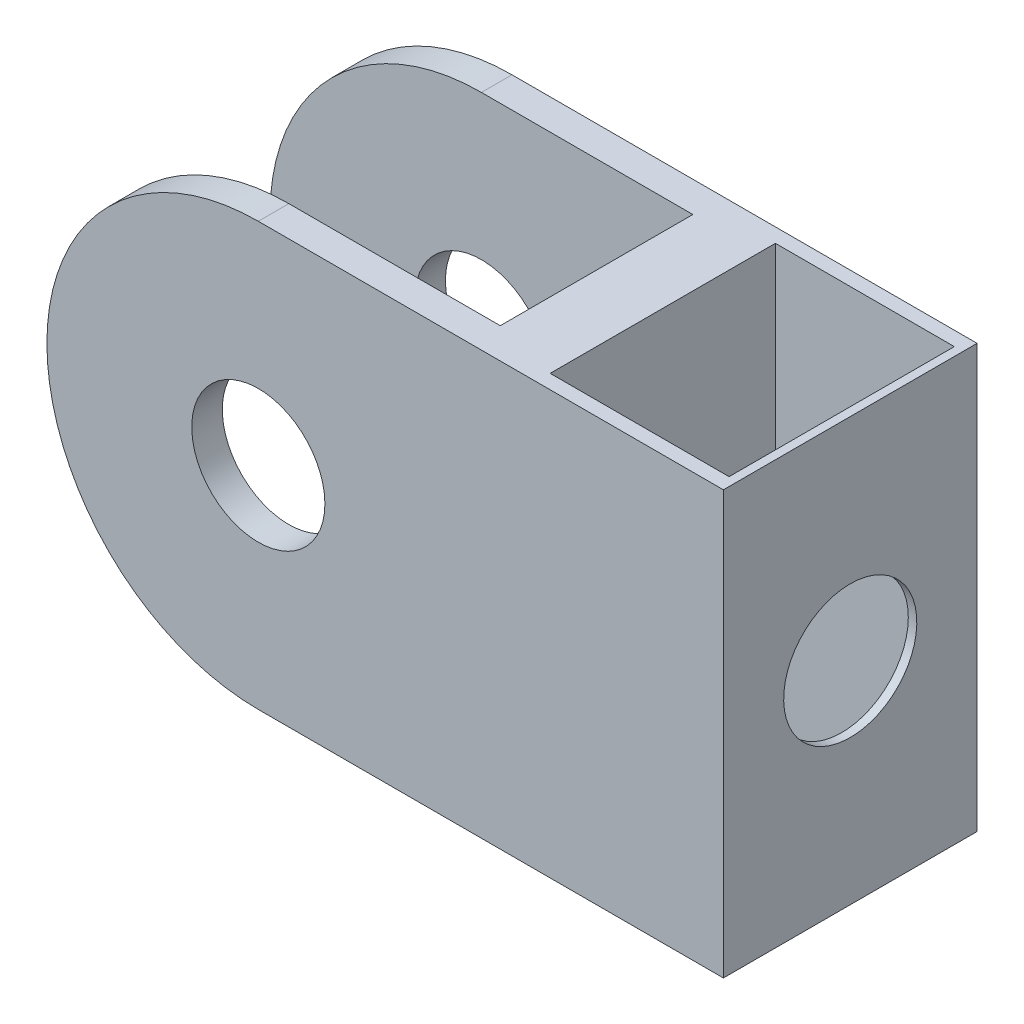
from build123d import *

# Parameters (mm, degrees)
SKETCH1_R           = 4
BOSS_EXTRUDE1_DEPTH = 15.24
SKETCH2_W           = 25.4
SKETCH2_H           = 11.5697
CUT_EXTRUDE1_DEPTH  = 26.4
SKETCH3_W           = 10.75005279
SKETCH3_H           = 13.530974344
CUT_EXTRUDE2_DEPTH  = 26.4
SKETCH4_R           = 4
CUT_EXTRUDE3_DEPTH  = 41.64


with BuildPart() as part:
    # Sketch1 → Boss-Extrude1 (new body)
    with BuildSketch(Plane.XY):
        with BuildLine():
            Line((0, 12.7), (27.94, 12.7))
            Line((27.94, 12.7), (27.94, -12.7))
            Line((27.94, -12.7), (0, -12.7))
            ThreePointArc((0, -12.7), (-12.7, 0), (0, 12.7))
        make_face()
        Circle(SKETCH1_R, mode=Mode.SUBTRACT)
    extrude(amount=BOSS_EXTRUDE1_DEPTH)

    # Sketch2 → Cut-Extrude1 (cut, through all)
    with BuildSketch(Plane(origin=(0, 12.7, 0), x_dir=(1, 0, 0), z_dir=(0, 1, 0))):
        with Locations((0, -7.62)):
            Rectangle(SKETCH2_W, SKETCH2_H)
    extrude(amount=-CUT_EXTRUDE1_DEPTH, mode=Mode.SUBTRACT)

    # Sketch3 → Cut-Extrude2 (cut, through all)
    with BuildSketch(Plane(origin=(0, 12.7, 0), x_dir=(1, 0, 0), z_dir=(0, 1, 0))):
        with Locations((22.053049583, -7.62)):
            Rectangle(SKETCH3_W, SKETCH3_H)
    extrude(amount=-CUT_EXTRUDE2_DEPTH, mode=Mode.SUBTRACT)

    # Sketch4 → Cut-Extrude3 (cut, through all)
    with BuildSketch(Plane(origin=(27.94, 0, 0), x_dir=(0, 0, -1), z_dir=(1, 0, 0))):
        with Locations((-7.62, 0)):
            Circle(SKETCH4_R)
    extrude(amount=-CUT_EXTRUDE3_DEPTH, mode=Mode.SUBTRACT)


solid = part.part
